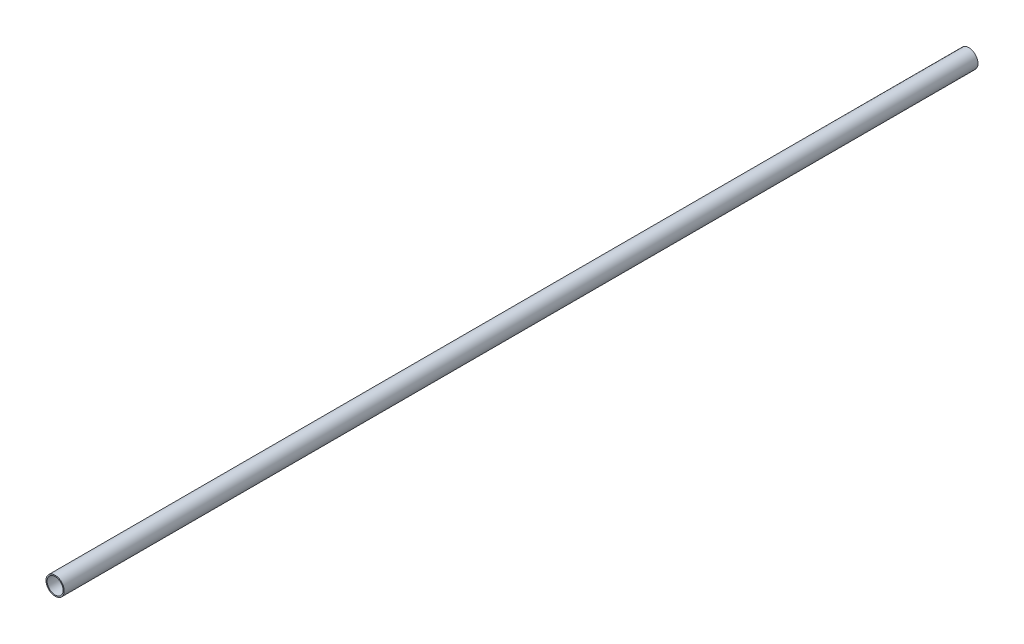
from build123d import *

# Parameters (mm, degrees)
ESQUISSE1_R        = 4
ESQUISSE1_R_2      = 3.5
BOSS_EXTRU_1_DEPTH = 400


with BuildPart() as part:
    # Esquisse1 → Boss.-Extru.1 (new body)
    with BuildSketch(Plane.XY):
        Circle(ESQUISSE1_R)
        Circle(ESQUISSE1_R_2, mode=Mode.SUBTRACT)
    extrude(amount=BOSS_EXTRU_1_DEPTH)


solid = part.part
